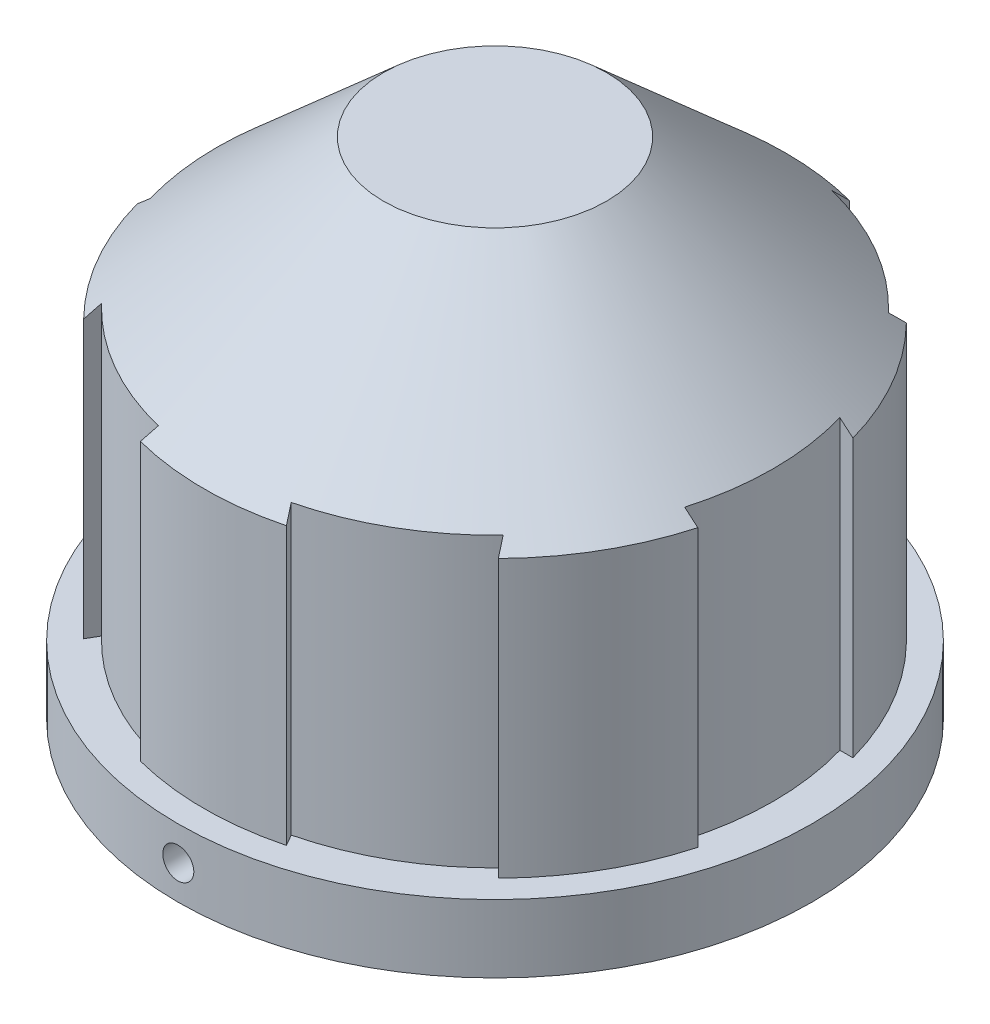
from build123d import *

# Parameters (mm, degrees)
CUT_EXTRUDE1_DEPTH        = 22.5
CIRPATTERN1_COUNT         = 6
M2X0_4_TAPPED_HOLE1_D     = 1.6
M2X0_4_TAPPED_HOLE1_DEPTH = 7
M2X0_4_TAPPED_HOLE1_TIP   = 0.480688495
M2X0_4_TAPPED_HOLE2_D     = 1.6
M2X0_4_TAPPED_HOLE2_DEPTH = 8.2
M2X0_4_TAPPED_HOLE2_TIP   = 0.480688495


with BuildPart() as part:
    # Sketch1 one side → Revolve3 (revolve)
    with BuildSketch(Plane.XY):
        Polygon((12.75, 0), (16.35, 0), (16.35, 3.5), (15, 3.5), (15, 17.778485378), (5.75, 26), (0, 26), (0, 24.5), (3.084626234, 24.5), (3.425, 5), (4.5, 5), (5.696502575, 23.37174091), (12.75, 17.102504994), align=None)
    revolve(axis=Axis((0, 0, 0), (0, 1, 0)))

    # Sketch2 → Cut-Extrude1 (cut)
    with BuildSketch(Plane(origin=(0, 26, 0), x_dir=(1, 0, 0), z_dir=(0, 1, 0))):
        with BuildLine():
            Line((13.781237245, -4), (14.456832295, -4))
            ThreePointArc((14.456832295, -4), (15, 0), (14.456832295, 4))
            Line((14.456832295, 4), (13.781237245, 4))
            ThreePointArc((13.781237245, 4), (14.35, 0), (13.781237245, -4))
        make_face()
    cut_extrude1 = extrude(amount=-CUT_EXTRUDE1_DEPTH, mode=Mode.SUBTRACT)

    # CirPattern1: Cut-Extrude1 ×6 about axis
    cirpattern1_axis = Axis((0, 0, 0), (0, 1, 0))
    for i in range(1, CIRPATTERN1_COUNT):
        add(cut_extrude1.rotate(cirpattern1_axis, i * 360 / CIRPATTERN1_COUNT), mode=Mode.SUBTRACT)

    # M2x0.4 Tapped Hole1
    with Locations(Plane.XY.offset(16.35)):
        with Locations((0, 1.75)):
            Hole(M2X0_4_TAPPED_HOLE1_D / 2, depth=M2X0_4_TAPPED_HOLE1_DEPTH)
            with Locations((0, 0, -(M2X0_4_TAPPED_HOLE1_DEPTH + M2X0_4_TAPPED_HOLE1_TIP / 2))):  # 118° drill point
                Cone(0, M2X0_4_TAPPED_HOLE1_D / 2, M2X0_4_TAPPED_HOLE1_TIP, mode=Mode.SUBTRACT)

    # M2x0.4 Tapped Hole2
    with Locations(Plane(origin=(0, 0, -16.35), x_dir=(-1, 0, 0), z_dir=(0, 0, -1))):
        with Locations((0, 1.75)):
            Hole(M2X0_4_TAPPED_HOLE2_D / 2, depth=M2X0_4_TAPPED_HOLE2_DEPTH)
            with Locations((0, 0, -(M2X0_4_TAPPED_HOLE2_DEPTH + M2X0_4_TAPPED_HOLE2_TIP / 2))):  # 118° drill point
                Cone(0, M2X0_4_TAPPED_HOLE2_D / 2, M2X0_4_TAPPED_HOLE2_TIP, mode=Mode.SUBTRACT)


solid = part.part
